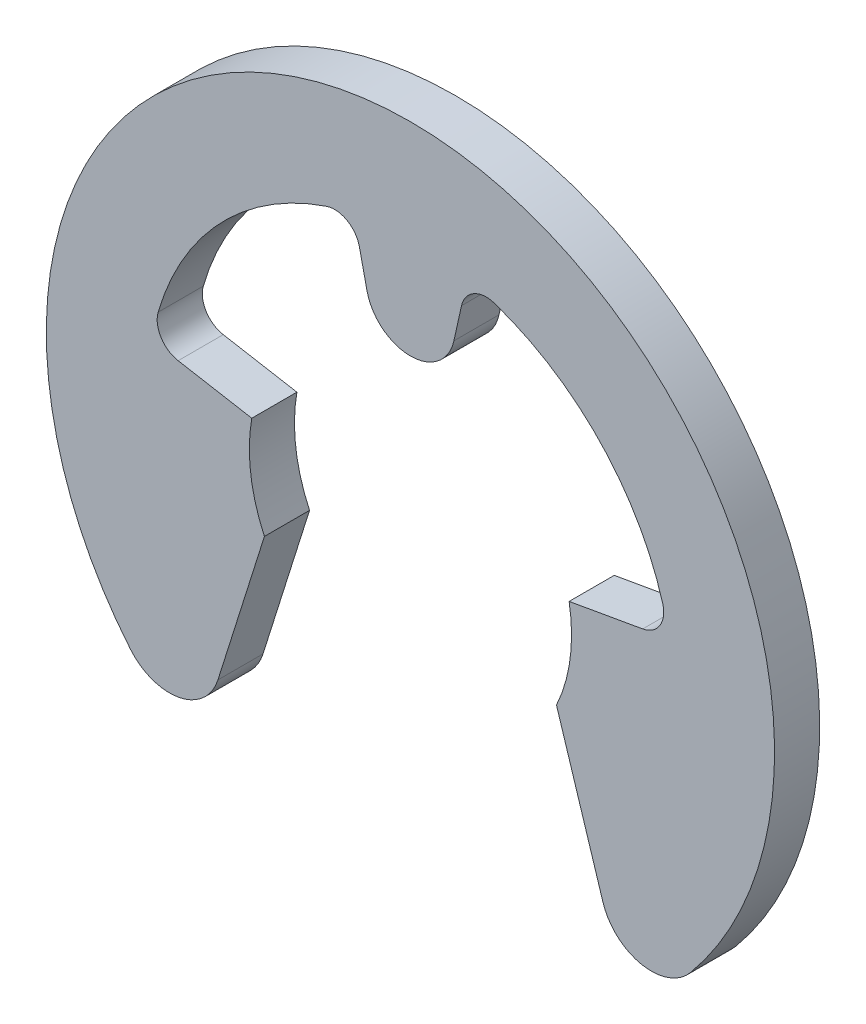
from build123d import *

# Parameters (mm, degrees)
BODY_DEPTH = 0.7


with BuildPart() as part:
    # BodySke → Body (new body)
    with BuildSketch(Plane.XY):
        with BuildLine():
            Line((2.462019383, 0.434120444), (3.604525865, 0.635575163))
            ThreePointArc((3.604525865, 0.635575163), (3.87032579, 0.815096078), (3.914382064, 1.132800979))
            ThreePointArc((3.914382064, 1.132800979), (2.943633145, 2.817915702), (1.302465751, 3.861244355))
            ThreePointArc((1.302465751, 3.861244355), (0.983141527, 3.831088106), (0.792197446, 3.573371756))
            Line((0.792197446, 3.573371756), (0.674195425, 3.041099035))
            ThreePointArc((0.674195425, 3.041099035), (0, 2.5), (-0.674195425, 3.041099035))
            Line((-0.674195425, 3.041099035), (-0.792197446, 3.573371756))
            ThreePointArc((-0.792197446, 3.573371756), (-0.983141527, 3.831088106), (-1.302465751, 3.861244355))
            ThreePointArc((-1.302465751, 3.861244355), (-2.943633145, 2.817915702), (-3.914382064, 1.132800979))
            ThreePointArc((-3.914382064, 1.132800979), (-3.87032579, 0.815096078), (-3.604525865, 0.635575163))
            Line((-3.604525865, 0.635575163), (-2.462019383, 0.434120444))
            ThreePointArc((-2.462019383, 0.434120444), (-2.478612153, -0.326315481), (-2.265769468, -1.056545654))
            Line((-2.265769468, -1.056545654), (-2.987597149, -3.345890578))
            ThreePointArc((-2.987597149, -3.345890578), (-3.586720395, -3.881790315), (-4.34413743, -3.612612627))
            ThreePointArc((-4.34413743, -3.612612627), (0, 5.65), (4.34413743, -3.612612627))
            ThreePointArc((4.34413743, -3.612612627), (3.586720395, -3.881790315), (2.987597149, -3.345890578))
            Line((2.987597149, -3.345890578), (2.265769468, -1.056545654))
            ThreePointArc((2.265769468, -1.056545654), (2.478612153, -0.326315481), (2.462019383, 0.434120444))
        make_face()
    extrude(amount=-BODY_DEPTH)


solid = part.part
